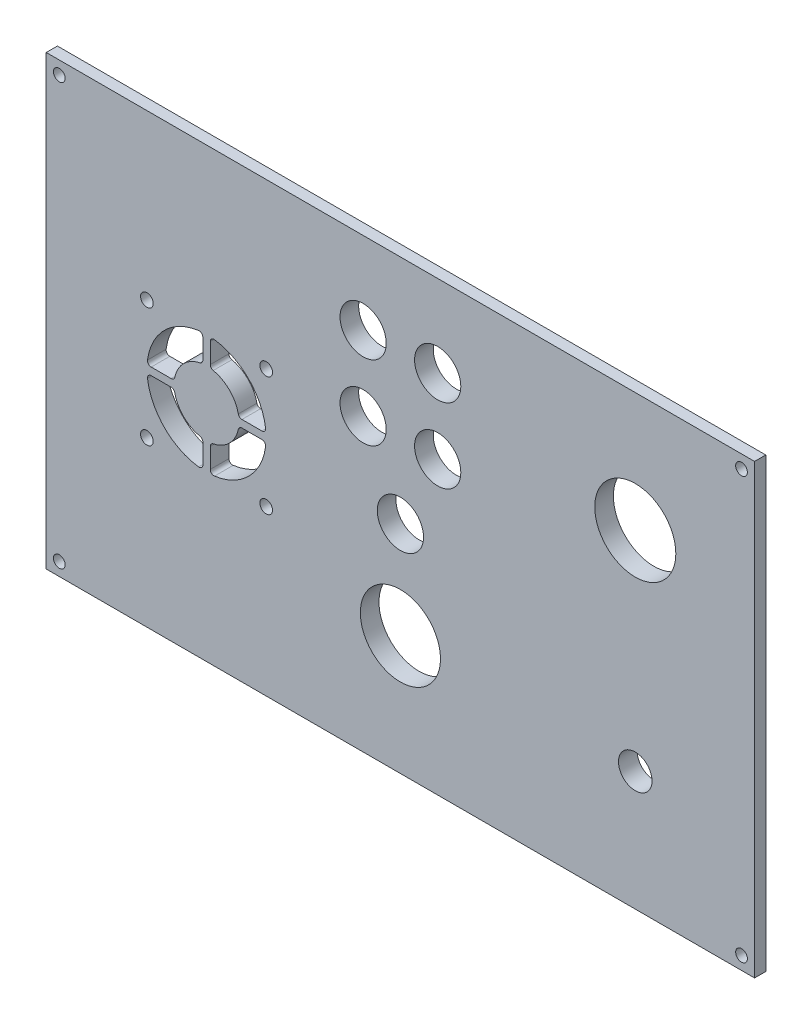
from build123d import *

# Parameters (mm, degrees)
SKETCH1_W               = 190
SKETCH1_H               = 120
SKETCH1_R               = 1.575
SKETCH1_R_2             = 1.7
SKETCH1_R_3             = 10.875
SKETCH1_R_4             = 10.75
SKETCH1_R_5             = 4.5
SKETCH1_R_6             = 6.2
BOSS_EXTRUDE1_DEPTH     = 5
SKETCH5_W               = 190
SKETCH5_H               = 120
CUT_EXTRUDE3_DEPTH      = 2
CUT_EXTRUDE3_DEPTH_BACK = 1
FILLET1_R               = 1
SKETCH6_R               = 1.875
CUT_EXTRUDE4_DEPTH      = 2.5


with BuildPart() as part:
    # Sketch1 → Boss-Extrude1 (new body)
    with BuildSketch(Plane.XY):
        Rectangle(SKETCH1_W, SKETCH1_H)
        with Locations((-91.5, 56.5)):
            Circle(SKETCH1_R, mode=Mode.SUBTRACT)
        with Locations((91.5, 56.5)):
            Circle(SKETCH1_R, mode=Mode.SUBTRACT)
        with Locations((91.5, -56.5)):
            Circle(SKETCH1_R, mode=Mode.SUBTRACT)
        with Locations((-91.5, -56.5)):
            Circle(SKETCH1_R, mode=Mode.SUBTRACT)
        with Locations((-36, 16)):
            Circle(SKETCH1_R_2, mode=Mode.SUBTRACT)
        with Locations((-36, -16)):
            Circle(SKETCH1_R_2, mode=Mode.SUBTRACT)
        with Locations((-68, -16)):
            Circle(SKETCH1_R_2, mode=Mode.SUBTRACT)
        with Locations((-68, 16)):
            Circle(SKETCH1_R_2, mode=Mode.SUBTRACT)
        with Locations((63, 28)):
            Circle(SKETCH1_R_3, mode=Mode.SUBTRACT)
        with Locations((0, -28)):
            Circle(SKETCH1_R_4, mode=Mode.SUBTRACT)
        with Locations((63, -28)):
            Circle(SKETCH1_R_5, mode=Mode.SUBTRACT)
        with Locations((-10, 38)):
            Circle(SKETCH1_R_6, mode=Mode.SUBTRACT)
        with Locations((10, 18)):
            Circle(SKETCH1_R_6, mode=Mode.SUBTRACT)
        with Locations((0, -2)):
            Circle(SKETCH1_R_6, mode=Mode.SUBTRACT)
        with Locations((-10, 18)):
            Circle(SKETCH1_R_6, mode=Mode.SUBTRACT)
        with Locations((10, 38)):
            Circle(SKETCH1_R_6, mode=Mode.SUBTRACT)
        with BuildLine():
            Line((-53, 8.645421567), (-53, 15.954278592))
            ThreePointArc((-53, 15.954278592), (-63.303517271, 11.303517271), (-67.954278592, 1))
            Line((-67.954278592, 1), (-60.645421567, 1))
            ThreePointArc((-60.645421567, 1), (-58.153995209, 6.153995209), (-53, 8.645421567))
        make_face(mode=Mode.SUBTRACT)
        with BuildLine():
            Line((-51, 8.645421567), (-51, 15.954278592))
            ThreePointArc((-51, 15.954278592), (-40.696482729, 11.303517271), (-36.045721408, 1))
            Line((-36.045721408, 1), (-43.354578433, 1))
            ThreePointArc((-43.354578433, 1), (-45.846004791, 6.153995209), (-51, 8.645421567))
        make_face(mode=Mode.SUBTRACT)
        with BuildLine():
            Line((-43.354578433, -1), (-36.045721408, -1))
            ThreePointArc((-36.045721408, -1), (-40.696482729, -11.303517271), (-51, -15.954278592))
            Line((-51, -15.954278592), (-51, -8.645421567))
            ThreePointArc((-51, -8.645421567), (-45.846004791, -6.153995209), (-43.354578433, -1))
        make_face(mode=Mode.SUBTRACT)
        with BuildLine():
            Line((-53, -8.645421567), (-53, -15.954278592))
            ThreePointArc((-53, -15.954278592), (-63.303517271, -11.303517271), (-67.954278592, -1))
            Line((-67.954278592, -1), (-60.645421567, -1))
            ThreePointArc((-60.645421567, -1), (-58.153995209, -6.153995209), (-53, -8.645421567))
        make_face(mode=Mode.SUBTRACT)
    extrude(amount=BOSS_EXTRUDE1_DEPTH)

    # Sketch5 → Cut-Extrude3 (cut, two sides)
    with BuildSketch(Plane.XY) as cut_extrude3_sk:
        Rectangle(SKETCH5_W, SKETCH5_H)
        Polygon((-87.5, 57.5), (87.5, 57.5), (87.5, 52.5), (92.5, 52.5), (92.5, -52.5), (87.5, -52.5), (87.5, -57.5), (-87.5, -57.5), (-87.5, -52.5), (-92.5, -52.5), (-92.5, 52.5), (-87.5, 52.5), align=None, mode=Mode.SUBTRACT)
    extrude(amount=CUT_EXTRUDE3_DEPTH, mode=Mode.SUBTRACT)
    extrude(cut_extrude3_sk.sketch, amount=-CUT_EXTRUDE3_DEPTH_BACK, mode=Mode.SUBTRACT)

    # Fillet1
    fillet1_edges = [part.edges().sort_by_distance(p)[0] for p in [
        (-43.354578433, -1, 2.5),
        (-51, -8.645421567, 2.5),
        (-51, -15.954278592, 2.5),
        (-36.045721408, -1, 2.5),
        (-53, -8.645421567, 2.5),
        (-60.645421567, -1, 2.5),
        (-67.954278592, -1, 2.5),
        (-53, -15.954278592, 2.5),
        (-60.645421567, 1, 2.5),
        (-53, 8.645421567, 2.5),
        (-53, 15.954278592, 2.5),
        (-67.954278592, 1, 2.5),
        (-51, 8.645421567, 2.5),
        (-43.354578433, 1, 2.5),
        (-36.045721408, 1, 2.5),
        (-51, 15.954278592, 2.5),
    ]]
    fillet(fillet1_edges, radius=FILLET1_R)

    # Sketch6 → Cut-Extrude4 (cut)
    with BuildSketch(Plane(origin=(0, 0, 0), x_dir=(-1, 0, 0), z_dir=(0, 0, -1))):
        with Locations((-72.6, -28)):
            Circle(SKETCH6_R)
    extrude(amount=-CUT_EXTRUDE4_DEPTH, mode=Mode.SUBTRACT)


solid = part.part
